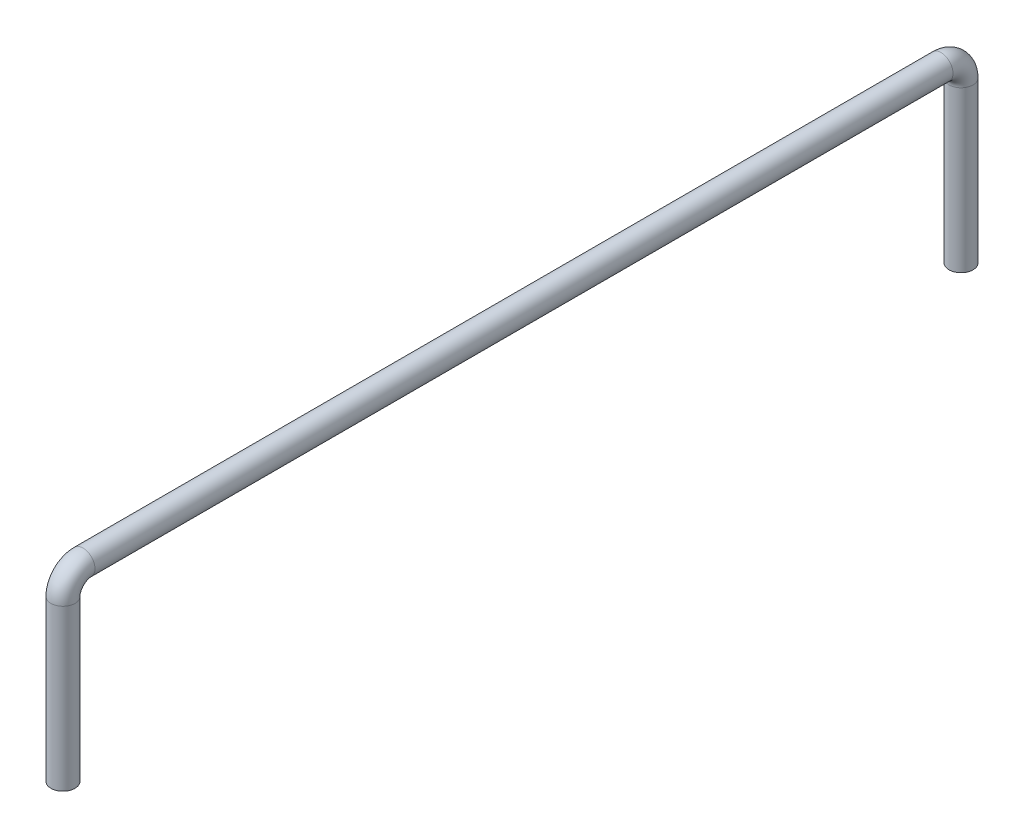
from build123d import *

# Parameters (mm, degrees)
SWEEP4_PROFILE_R = 0.6


with BuildPart() as part:
    # Sweep4: sweep along a path in Sketch4
    with BuildLine(Plane(origin=(0, 0, 0), x_dir=(0, 0, -1), z_dir=(1, 0, 0))) as sweep4_path:
        Line((0, 0), (0, 8))
        ThreePointArc((0, 8), (-0.292893219, 8.707106781), (-1, 9))
        Line((-1, 9), (-43.85922, 9))
        ThreePointArc((-43.85922, 9), (-44.566326781, 8.707106781), (-44.85922, 8))
        Line((-44.85922, 8), (-44.85922, 0))
    # Sweep4 profile (on start of the path) → Sweep4 (sweep)
    with BuildSketch(Plane.ZX):
        Circle(SWEEP4_PROFILE_R)
    sweep(path=sweep4_path.line)


solid = part.part
